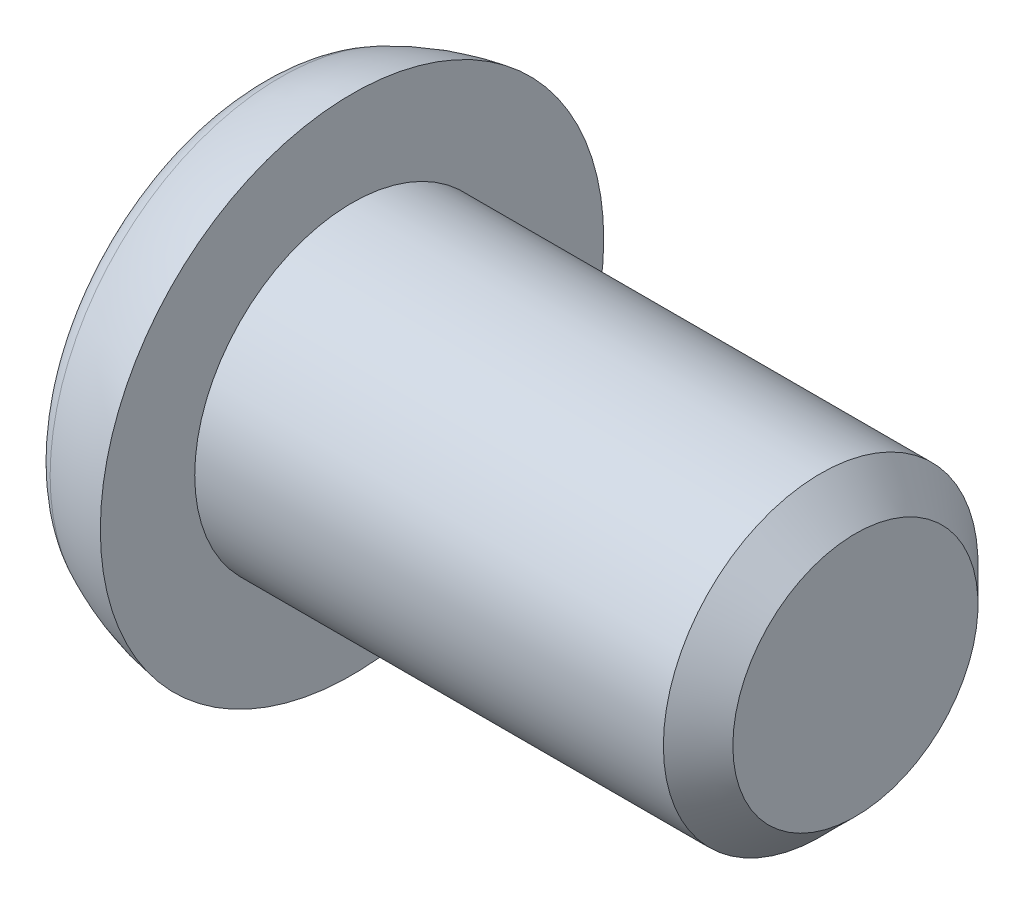
from build123d import *

# Parameters (mm, degrees)
CUT_EXTRUDE1_DEPTH      = 0.2
CUT_EXTRUDE1_DEPTH_BACK = 0.2
CUT_EXTRUDE2_DEPTH      = 0.2
CUT_EXTRUDE2_DEPTH_BACK = 0.2


with BuildPart() as part:
    # Sketch1 → Revolve1 (revolve)
    with BuildSketch(Plane.XY):
        with BuildLine():
            Line((-0.8, 0), (-0.8, 1.46601855))
            ThreePointArc((-0.8, 1.46601855), (-0.738085774, 1.679789478), (-0.571509952, 1.827383098))
            ThreePointArc((-0.571509952, 1.827383098), (-0.29223212, 1.93513645), (0, 2))
            Line((0, 2), (0, 1.25))
            Line((0, 1.25), (3.724, 1.25))
            Line((3.724, 1.25), (4, 0.974))
            Line((4, 0.974), (4, 0))
            Line((4, 0), (-0.8, 0))
        make_face()
    revolve(axis=Axis((4, 0, 0), (-1, 0, 0)))

    # Sketch2 → Cut-Extrude1 (cut, two sides: drawn at the far end of the back side and taken through both)
    with BuildSketch(Plane.XY.offset(-CUT_EXTRUDE1_DEPTH_BACK)):
        with BuildLine():
            Line((-0.8, 1), (-0.8, -1))
            ThreePointArc((-0.8, -1), (-0.115415221, -0.639534952), (0.32, 0))
            ThreePointArc((0.32, 0), (-0.115415221, 0.639534952), (-0.8, 1))
        make_face()
    extrude(amount=CUT_EXTRUDE1_DEPTH + CUT_EXTRUDE1_DEPTH_BACK, mode=Mode.SUBTRACT)

    # Sketch3 → Cut-Extrude2 (cut, two sides: drawn at the far end of the back side and taken through both)
    with BuildSketch(Plane(origin=(0, 0, 0), x_dir=(1, 0, 0), z_dir=(0, 1, 0)).offset(-CUT_EXTRUDE2_DEPTH_BACK)):
        with BuildLine():
            Line((-0.8, 1), (-0.8, -1))
            ThreePointArc((-0.8, -1), (-0.115415221, -0.639534952), (0.32, 0))
            ThreePointArc((0.32, 0), (-0.115415221, 0.639534952), (-0.8, 1))
        make_face()
    extrude(amount=CUT_EXTRUDE2_DEPTH + CUT_EXTRUDE2_DEPTH_BACK, mode=Mode.SUBTRACT)


solid = part.part
